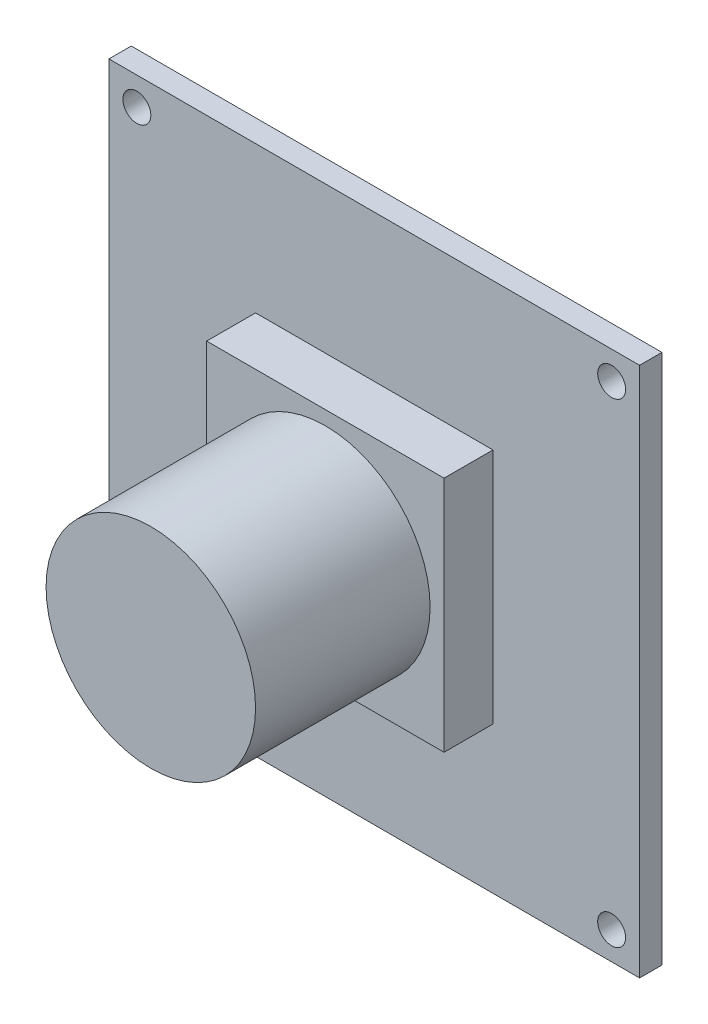
from build123d import *

# Parameters (mm, degrees)
SKETCH1_W           = 38
SKETCH1_H           = 38
BOSS_EXTRUDE1_DEPTH = 1.6
SKETCH2_W           = 17
SKETCH2_H           = 17
BOSS_EXTRUDE2_DEPTH = 3.5
SKETCH3_R           = 7.5
BOSS_EXTRUDE3_DEPTH = 12.5
CUT_EXTRUDE1_REACH  = 3.6
SKETCH4_R           = 1
SKETCH5_W           = 10
SKETCH5_H           = 5
BOSS_EXTRUDE4_DEPTH = 8


with BuildPart() as part:
    # Sketch1 → Boss-Extrude1 (new body)
    with BuildSketch(Plane.XY):
        Rectangle(SKETCH1_W, SKETCH1_H)
    extrude(amount=-BOSS_EXTRUDE1_DEPTH)

    # Sketch2 → Boss-Extrude2 (add)
    with BuildSketch(Plane.XY):
        Rectangle(SKETCH2_W, SKETCH2_H)
    extrude(amount=BOSS_EXTRUDE2_DEPTH)

    # Sketch3 → Boss-Extrude3 (add)
    with BuildSketch(Plane.XY.offset(3.5)):
        Circle(SKETCH3_R)
    extrude(amount=BOSS_EXTRUDE3_DEPTH)

    # Sketch4 → Cut-Extrude1 (cut, up to next)
    with BuildSketch(Plane.XY, mode=Mode.PRIVATE) as cut_extrude1_sk1:
        with Locations((-17, 17)):
            Circle(SKETCH4_R)
    cut_extrude1_tool1 = extrude(cut_extrude1_sk1.sketch, amount=-CUT_EXTRUDE1_REACH, mode=Mode.PRIVATE) & part.part
    add(cut_extrude1_tool1.solids().sort_by_distance((-17, 17, 0))[0], mode=Mode.SUBTRACT)
    # Sketch4 → Cut-Extrude1 (cut, up to next)
    with BuildSketch(Plane.XY, mode=Mode.PRIVATE) as cut_extrude1_sk2:
        with Locations((17, 17)):
            Circle(SKETCH4_R)
    cut_extrude1_tool2 = extrude(cut_extrude1_sk2.sketch, amount=-CUT_EXTRUDE1_REACH, mode=Mode.PRIVATE) & part.part
    add(cut_extrude1_tool2.solids().sort_by_distance((17, 17, 0))[0], mode=Mode.SUBTRACT)
    # Sketch4 → Cut-Extrude1 (cut, up to next)
    with BuildSketch(Plane.XY, mode=Mode.PRIVATE) as cut_extrude1_sk3:
        with Locations((-17, -17)):
            Circle(SKETCH4_R)
    cut_extrude1_tool3 = extrude(cut_extrude1_sk3.sketch, amount=-CUT_EXTRUDE1_REACH, mode=Mode.PRIVATE) & part.part
    add(cut_extrude1_tool3.solids().sort_by_distance((-17, -17, 0))[0], mode=Mode.SUBTRACT)
    # Sketch4 → Cut-Extrude1 (cut, up to next)
    with BuildSketch(Plane.XY, mode=Mode.PRIVATE) as cut_extrude1_sk4:
        with Locations((17, -17)):
            Circle(SKETCH4_R)
    cut_extrude1_tool4 = extrude(cut_extrude1_sk4.sketch, amount=-CUT_EXTRUDE1_REACH, mode=Mode.PRIVATE) & part.part
    add(cut_extrude1_tool4.solids().sort_by_distance((17, -17, 0))[0], mode=Mode.SUBTRACT)

    # Sketch5 → Boss-Extrude4 (add)
    with BuildSketch(Plane(origin=(0, 0, -1.6), x_dir=(-1, 0, 0), z_dir=(0, 0, -1))):
        with Locations((-5, -13.5)):
            Rectangle(SKETCH5_W, SKETCH5_H)
    extrude(amount=BOSS_EXTRUDE4_DEPTH)


solid = part.part
